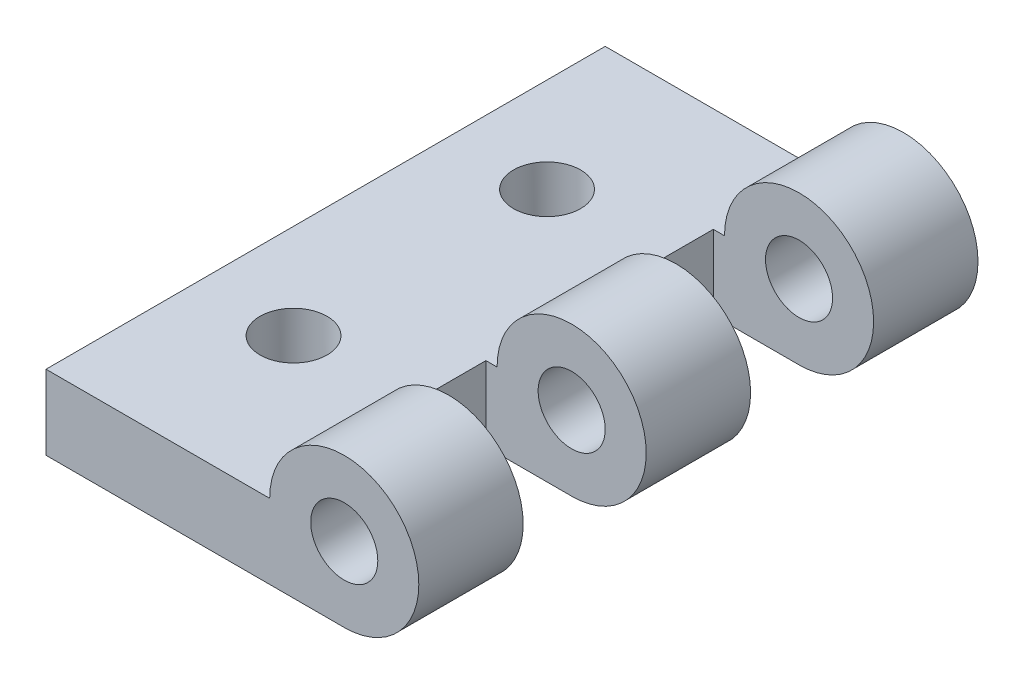
from build123d import *

# Parameters (mm, degrees)
SKETCH1_R               = 2.286
BOSS_EXTRUDE1_DEPTH     = 38.1
SKETCH2_W               = 10.922
SKETCH2_H               = 8.382
CUT_EXTRUDE1_DEPTH      = 6.08
CUT_EXTRUDE1_DEPTH_BACK = 6.08
SKETCH3_R               = 2.286
CUT_EXTRUDE2_DEPTH      = 6.08
CUT_EXTRUDE2_DEPTH_BACK = 6.08


with BuildPart() as part:
    # Sketch1 → Boss-Extrude1 (new body)
    with BuildSketch(Plane.XY):
        with BuildLine():
            Line((0, 5.08), (15.24, 5.08))
            ThreePointArc((15.24, 5.08), (23.912102448, 8.672102448), (20.32, 0))
            Line((20.32, 0), (0, 0))
            Line((0, 0), (0, 5.08))
        make_face()
        with Locations((20.32, 5.08)):
            Circle(SKETCH1_R, mode=Mode.SUBTRACT)
    extrude(amount=BOSS_EXTRUDE1_DEPTH)

    # Sketch2 → Cut-Extrude1 (cut, two sides)
    with BuildSketch(Plane(origin=(0, 5.08, 0), x_dir=(1, 0, 0), z_dir=(0, 1, 0))) as cut_extrude1_sk:
        with Locations((19.939, -11.303)):
            Rectangle(SKETCH2_W, SKETCH2_H)
        with Locations((19.939, -26.797)):
            Rectangle(SKETCH2_W, SKETCH2_H)
    extrude(amount=CUT_EXTRUDE1_DEPTH, mode=Mode.SUBTRACT)
    extrude(cut_extrude1_sk.sketch, amount=-CUT_EXTRUDE1_DEPTH_BACK, mode=Mode.SUBTRACT)

    # Sketch3 → Cut-Extrude2 (cut, two sides)
    with BuildSketch(Plane(origin=(0, 5.08, 0), x_dir=(1, 0, 0), z_dir=(0, 1, 0))) as cut_extrude2_sk:
        with Locations((6.4516, -10.414)):
            Circle(SKETCH3_R)
        with Locations((6.4516, -27.686)):
            Circle(SKETCH3_R)
    extrude(amount=CUT_EXTRUDE2_DEPTH, mode=Mode.SUBTRACT)
    extrude(cut_extrude2_sk.sketch, amount=-CUT_EXTRUDE2_DEPTH_BACK, mode=Mode.SUBTRACT)


solid = part.part
